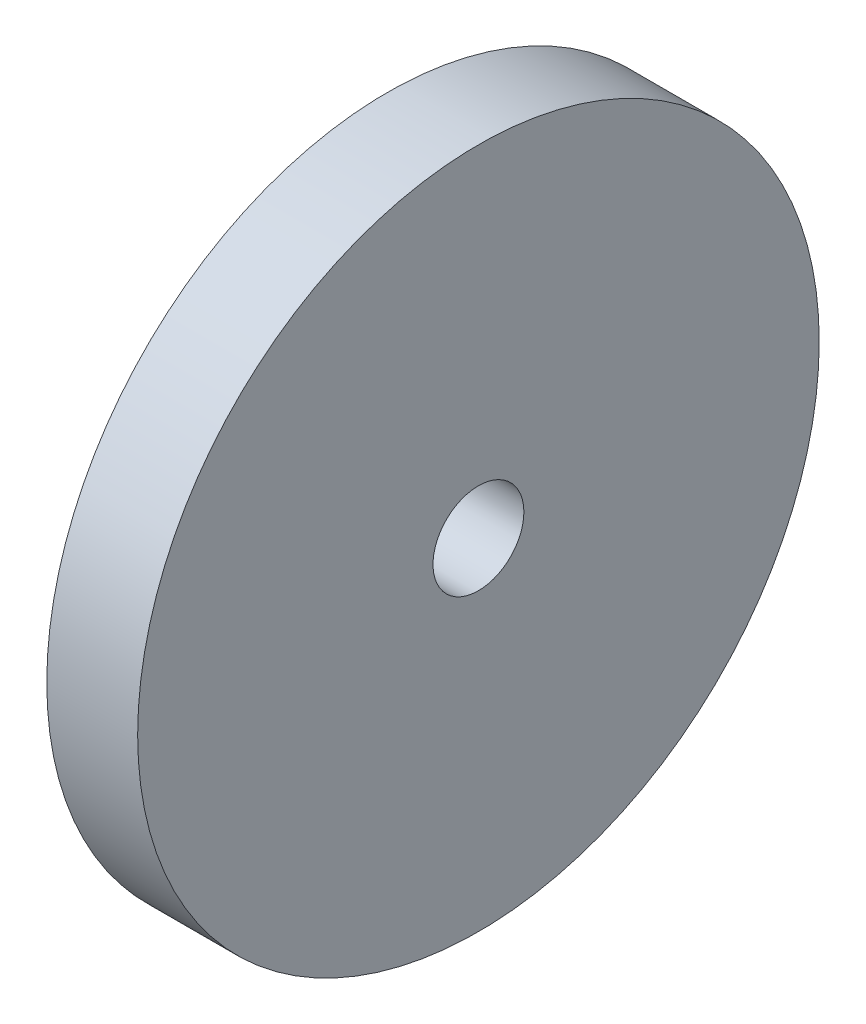
from build123d import *

# Parameters (mm, degrees)
SCHIZZO1_R                   = 30
ESTRUSIONE_ESTRUSIONE1_DEPTH = 8
SCHIZZO3_R                   = 4
TAGLIO_ESTRUSIONE1_DEPTH     = 9


with BuildPart() as part:
    # Schizzo1 → Estrusione-Estrusione1 (new body)
    with BuildSketch(Plane(origin=(0, 0, 0), x_dir=(0, 0, -1), z_dir=(1, 0, 0))):
        Circle(SCHIZZO1_R)
    extrude(amount=ESTRUSIONE_ESTRUSIONE1_DEPTH)

    # Schizzo3 → Taglio-Estrusione1 (cut, through all)
    with BuildSketch(Plane(origin=(8, 0, 0), x_dir=(0, 0, -1), z_dir=(1, 0, 0))):
        Circle(SCHIZZO3_R)
    extrude(amount=-TAGLIO_ESTRUSIONE1_DEPTH, mode=Mode.SUBTRACT)


solid = part.part
